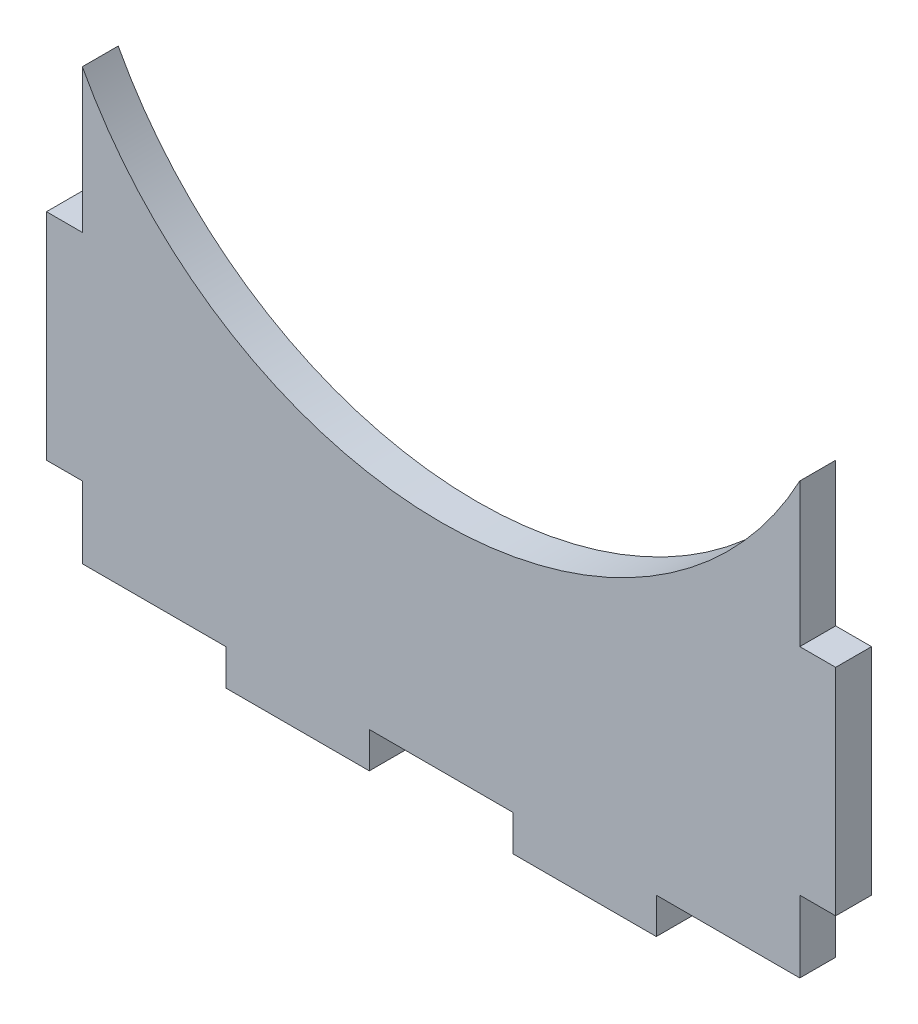
from build123d import *

# Parameters (mm, degrees)
BOSS_EXTRUDE1_DEPTH = 6.35


with BuildPart() as part:
    # Sketch1 → Boss-Extrude1 (new body)
    with BuildSketch(Plane.XY):
        with BuildLine():
            Line((63.5, 6.35), (63.5, 19.05))
            Line((63.5, 19.05), (69.85, 19.05))
            Line((69.85, 19.05), (69.85, 57.15))
            Line((69.85, 57.15), (63.5, 57.15))
            Line((63.5, 57.15), (63.5, 82.55))
            ThreePointArc((63.5, 82.55), (0, 44.45), (-63.5, 82.55))
            Line((-63.5, 82.55), (-63.5, 57.15))
            Line((-63.5, 57.15), (-69.85, 57.15))
            Line((-69.85, 57.15), (-69.85, 19.05))
            Line((-69.85, 19.05), (-63.5, 19.05))
            Line((-63.5, 19.05), (-63.5, 6.35))
            Line((-63.5, 6.35), (-38.1, 6.35))
            Line((-38.1, 6.35), (-38.1, 0))
            Line((-38.1, 0), (-12.7, 0))
            Line((-12.7, 0), (-12.7, 6.35))
            Line((-12.7, 6.35), (12.7, 6.35))
            Line((12.7, 6.35), (12.7, 0))
            Line((12.7, 0), (38.1, 0))
            Line((38.1, 0), (38.1, 6.35))
            Line((38.1, 6.35), (63.5, 6.35))
        make_face()
    extrude(amount=BOSS_EXTRUDE1_DEPTH)


solid = part.part
